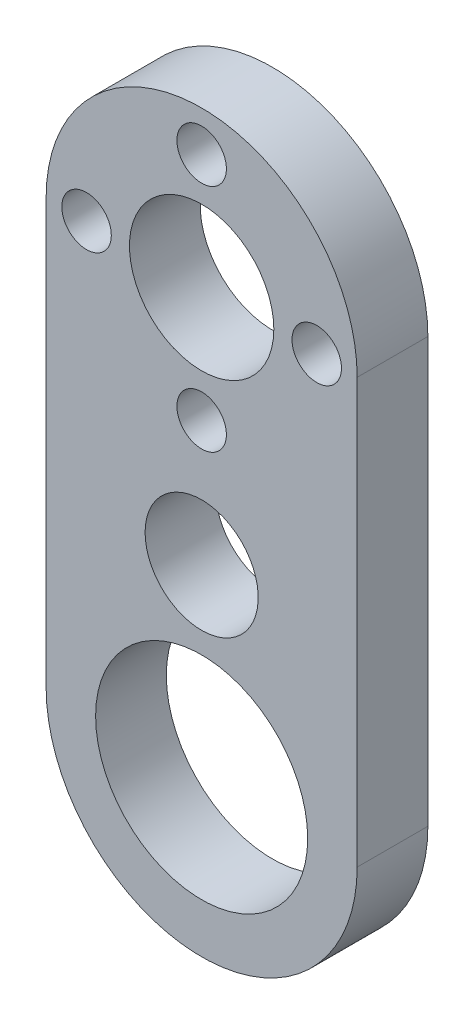
from build123d import *

# Parameters (mm, degrees)
ESBO_O1_R                = 11
ESBO_O1_R_2              = 5.105
RESSALTO_EXTRUS_O1_DEPTH = 5
ESBO_O2_R                = 1.75
CORTE_EXTRUS_O1_DEPTH    = 5
PADR_OCIRCULAR1_COUNT    = 4
ESBO_O3_R                = 7.5
ESBO_O3_R_2              = 4
RESSALTO_EXTRUS_O2_DEPTH = 5


with BuildPart() as part:
    # Esboço1 → Ressalto-extrusão1 (new body)
    with BuildSketch(Plane.XY):
        Circle(ESBO_O1_R)
        Circle(ESBO_O1_R_2, mode=Mode.SUBTRACT)
    extrude(amount=RESSALTO_EXTRUS_O1_DEPTH)

    # Esboço2 → Corte-extrusão1 (cut)
    with BuildSketch(Plane(origin=(0, 0, 0), x_dir=(-1, 0, 0), z_dir=(0, 0, -1))):
        with Locations((0, -8.14)):
            Circle(ESBO_O2_R)
    corte_extrus_o1 = extrude(amount=-CORTE_EXTRUS_O1_DEPTH, mode=Mode.SUBTRACT)

    # PadrãoCircular1: Corte-extrusão1 ×4 about axis
    padr_ocircular1_axis = Axis((0, 0, 0), (0, 0, 1))
    for i in range(1, PADR_OCIRCULAR1_COUNT):
        add(corte_extrus_o1.rotate(padr_ocircular1_axis, i * 360 / PADR_OCIRCULAR1_COUNT), mode=Mode.SUBTRACT)

    # Esboço3 → Ressalto-extrusão2 (add)
    with BuildSketch(Plane(origin=(0, 0, 0), x_dir=(-1, 0, 0), z_dir=(0, 0, -1))):
        with BuildLine():
            Line((-11, 0), (-11, -30))
            ThreePointArc((-11, -30), (0, -41), (11, -30))
            Line((11, -30), (11, 0))
            ThreePointArc((11, 0), (0, -11), (-11, 0))
        make_face()
        with Locations((0, -30)):
            Circle(ESBO_O3_R, mode=Mode.SUBTRACT)
        with Locations((0, -17)):
            Circle(ESBO_O3_R_2, mode=Mode.SUBTRACT)
    extrude(amount=-RESSALTO_EXTRUS_O2_DEPTH)


solid = part.part
